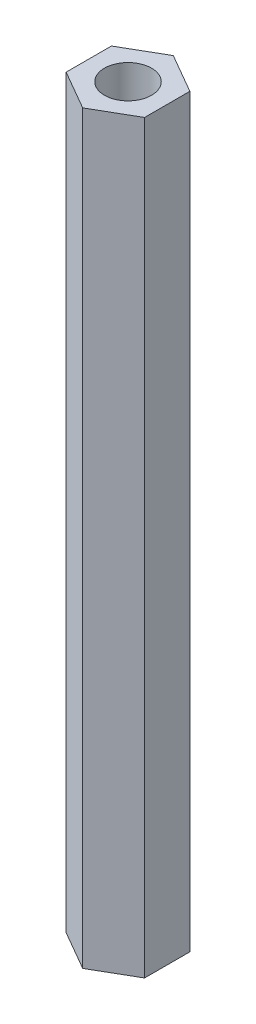
from build123d import *

# Parameters (mm, degrees)
SKETCH_1_R      = 1.5
EXTRUDE_1_DEPTH = 47.5


with BuildPart() as part:
    # Эскиз1 → Бобышка-Вытянуть1 (new body)
    with BuildSketch(Plane(origin=(0, 0, 0), x_dir=(1, 0, 0), z_dir=(0, 1, 0))):
        Polygon((0, -2.886751346), (2.5, -1.443375673), (2.5, 1.443375673), (0, 2.886751346), (-2.5, 1.443375673), (-2.5, -1.443375673), align=None)
        Circle(SKETCH_1_R, mode=Mode.SUBTRACT)
    extrude(amount=EXTRUDE_1_DEPTH)


solid = part.part
